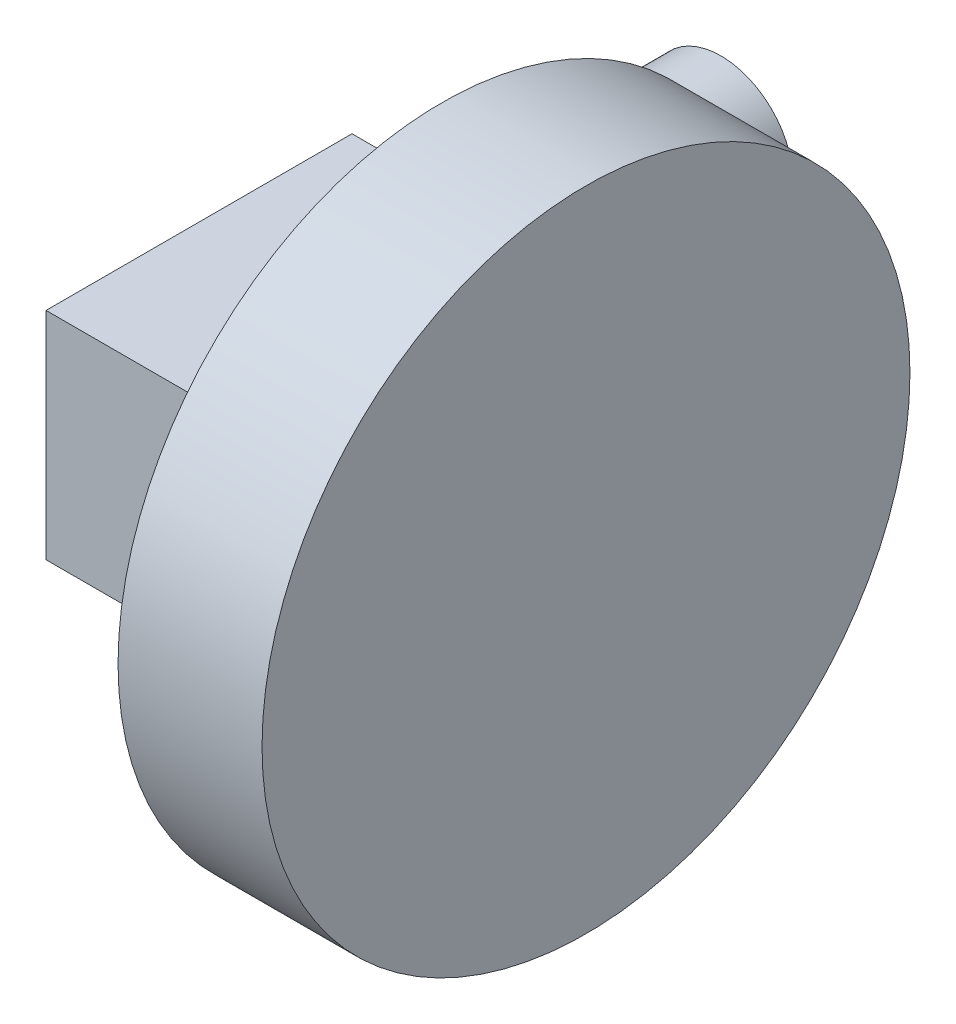
from build123d import *

# Parameters (mm, degrees)
SKETCH1_W           = 170
SKETCH1_H           = 120
BOSS_EXTRUDE1_DEPTH = 90
SKETCH5_R           = 40
BOSS_EXTRUDE3_DEPTH = 160
SKETCH7_R           = 5
BOSS_EXTRUDE4_DEPTH = 50
SKETCH8_R           = 180
BOSS_EXTRUDE5_DEPTH = 80


with BuildPart() as part:
    # Sketch1 → Boss-Extrude1 (new body)
    with BuildSketch(Plane(origin=(0, 0, 0), x_dir=(0, 0, -1), z_dir=(1, 0, 0))):
        with Locations((85, 60)):
            Rectangle(SKETCH1_W, SKETCH1_H)
    extrude(amount=BOSS_EXTRUDE1_DEPTH)

    # Sketch5 → Boss-Extrude3 (add)
    with BuildSketch(Plane(origin=(0, 0, -170), x_dir=(-1, 0, 0), z_dir=(0, 0, -1))):
        with Locations((-45, 60)):
            Circle(SKETCH5_R)
    extrude(amount=BOSS_EXTRUDE3_DEPTH)

    # Sketch7 → Boss-Extrude4 (add)
    with BuildSketch(Plane(origin=(90, 0, 0), x_dir=(0, 0, -1), z_dir=(1, 0, 0))):
        with Locations((80, 70)):
            Circle(SKETCH7_R)
    extrude(amount=BOSS_EXTRUDE4_DEPTH)

    # Sketch8 → Boss-Extrude5 (add)
    with BuildSketch(Plane(origin=(140, 0, 0), x_dir=(0, 0, -1), z_dir=(1, 0, 0))):
        with Locations((80, 70)):
            Circle(SKETCH8_R)
    extrude(amount=BOSS_EXTRUDE5_DEPTH)


solid = part.part
